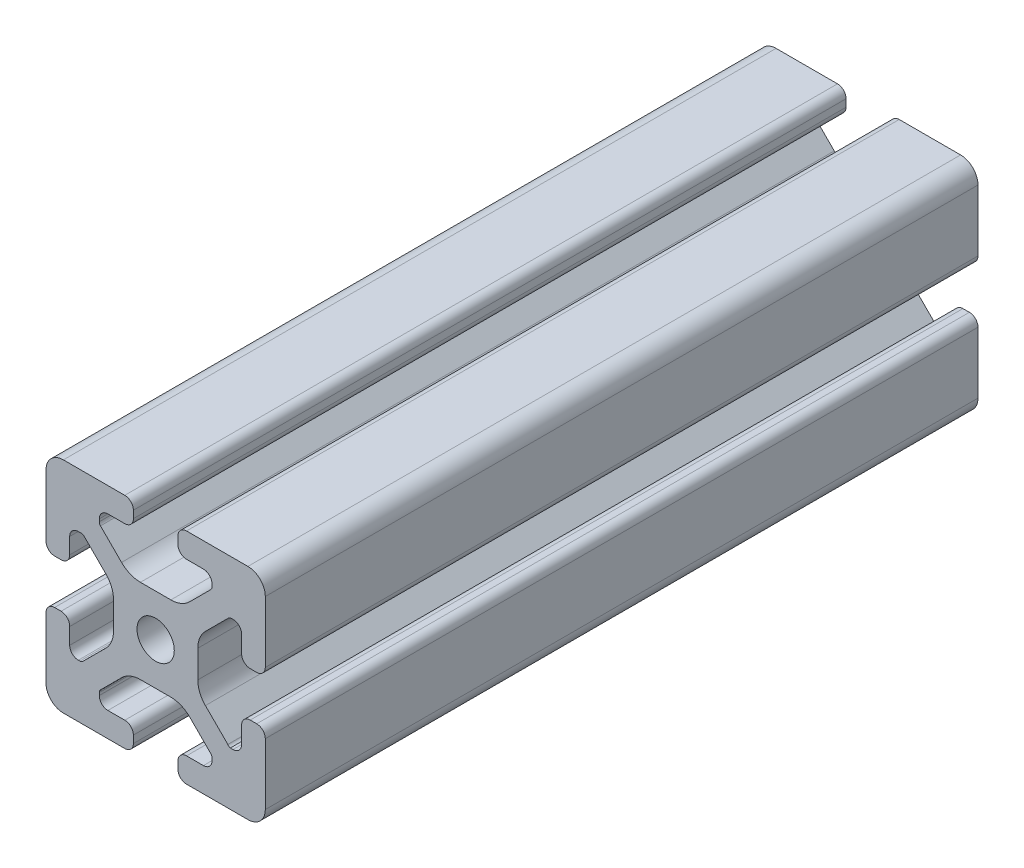
from build123d import *

# Parameters (mm, degrees)
SKETCH1_R      = 3.4
EXTRUDE1_DEPTH = 130


with BuildPart() as part:
    # Sketch1 → Extrude1 (new body)
    with BuildSketch(Plane.XY):
        with BuildLine():
            Line((-8.715, -15.524615034), (-5.63, -15.524615034))
            ThreePointArc((-5.63, -15.524615034), (-4.519842354, -15.984457388), (-4.06, -17.094615034))
            Line((-4.06, -17.094615034), (-4.06, -18.43))
            ThreePointArc((-4.06, -18.43), (-4.519842354, -19.540157646), (-5.63, -20))
            Line((-5.63, -20), (-16.674615034, -20))
            ThreePointArc((-16.674615034, -20), (-18.951578385, -19.194274381), (-20, -17.018368134))
            Line((-20, -17.018368134), (-20, -5.757918808))
            ThreePointArc((-20, -5.757918808), (-19.564709668, -4.603883664), (-18.43, -4.120449326))
            Line((-18.43, -4.120449326), (-17.25, -4.120449326))
            ThreePointArc((-17.25, -4.120449326), (-16.115287682, -4.60388249), (-15.67999625, -5.757919334))
            Line((-15.67999625, -5.757919334), (-15.67999625, -8.715399492))
            ThreePointArc((-15.67999625, -8.715399492), (-15.220153896, -9.825557139), (-14.10999625, -10.285399492))
            Line((-14.10999625, -10.285399492), (-13.816898819, -10.285399492))
            ThreePointArc((-13.816898819, -10.285399492), (-13.526061711, -10.227547119), (-13.279501941, -10.062800646))
            Line((-13.279501941, -10.062800646), (-9.076242789, -5.859541495))
            ThreePointArc((-9.076242789, -5.859541495), (-8.046572221, -4.318530588), (-7.685, -2.500784284))
            Line((-7.685, -2.500784284), (-7.685, 2.500784284))
            ThreePointArc((-7.685, 2.500784284), (-8.046572221, 4.318530588), (-9.076242789, 5.859541495))
            Line((-9.076242789, 5.859541495), (-13.040489136, 9.823787841))
            ThreePointArc((-13.040489136, 9.823787841), (-13.354224618, 10.012729352), (-13.71989919, 10.033001362))
            Line((-13.71989919, 10.033001362), (-14.05520779, 10.044710596))
            ThreePointArc((-14.05520779, 10.044710596), (-15.200613642, 9.605030484), (-15.68, 8.475666998))
            Line((-15.68, 8.475666998), (-15.68, 5.572979049))
            ThreePointArc((-15.68, 5.572979049), (-16.139842354, 4.462821403), (-17.25, 4.002979049))
            Line((-17.25, 4.002979049), (-18.43, 4.002979049))
            ThreePointArc((-18.43, 4.002979049), (-19.540157646, 4.462821403), (-20, 5.572979049))
            Line((-20, 5.572979049), (-20, 13.004526564))
            Line((-20, 13.004526564), (-20, 16.83))
            ThreePointArc((-20, 16.83), (-19.071528496, 19.071528496), (-16.83, 20))
            Line((-16.83, 20), (-5.63, 20))
            ThreePointArc((-5.63, 20), (-4.519842354, 19.540157646), (-4.06, 18.43))
            Line((-4.06, 18.43), (-4.06, 17.094615034))
            ThreePointArc((-4.06, 17.094615034), (-4.519842354, 15.984457388), (-5.63, 15.524615034))
            Line((-5.63, 15.524615034), (-8.715, 15.524615034))
            ThreePointArc((-8.715, 15.524615034), (-9.825157646, 15.06477268), (-10.285, 13.954615034))
            Line((-10.285, 13.954615034), (-10.285, 13.492503602))
            ThreePointArc((-10.285, 13.492503602), (-10.227148445, 13.201664194), (-10.062401154, 12.955102448))
            Line((-10.062401154, 12.955102448), (-6.217092793, 9.109794088))
            ThreePointArc((-6.217092793, 9.109794088), (-4.63891877, 8.055291919), (-2.777335583, 7.685))
            Line((-2.777335583, 7.685), (2.777335583, 7.685))
            ThreePointArc((2.777335583, 7.685), (4.63891877, 8.055291919), (6.217092793, 9.109794088))
            Line((6.217092793, 9.109794088), (10.062401154, 12.955102448))
            ThreePointArc((10.062401154, 12.955102448), (10.227148445, 13.201664194), (10.285, 13.492503602))
            Line((10.285, 13.492503602), (10.285, 13.954615034))
            ThreePointArc((10.285, 13.954615034), (9.825157646, 15.06477268), (8.715, 15.524615034))
            Line((8.715, 15.524615034), (5.63, 15.524615034))
            ThreePointArc((5.63, 15.524615034), (4.519842354, 15.984457388), (4.06, 17.094615034))
            Line((4.06, 17.094615034), (4.06, 18.43))
            ThreePointArc((4.06, 18.43), (4.519842354, 19.540157646), (5.63, 20))
            Line((5.63, 20), (12.979635074, 20))
            Line((12.979635074, 20), (16.83, 20))
            ThreePointArc((16.83, 20), (19.071528496, 19.071528496), (20, 16.83))
            Line((20, 16.83), (20, 13.001098436))
            Line((20, 13.001098436), (20, 5.63))
            ThreePointArc((20, 5.63), (19.540157461, 4.519842693), (18.43, 4.060000526))
            Line((18.43, 4.060000526), (17.24999625, 4.060000526))
            ThreePointArc((17.24999625, 4.060000526), (16.139838603, 4.519842879), (15.67999625, 5.630000526))
            Line((15.67999625, 5.630000526), (15.67999625, 8.715399492))
            ThreePointArc((15.67999625, 8.715399492), (15.220153896, 9.825557139), (14.10999625, 10.285399492))
            Line((14.10999625, 10.285399492), (13.816903094, 10.285399492))
            ThreePointArc((13.816903094, 10.285399492), (13.526063686, 10.227547937), (13.279501941, 10.062800646))
            Line((13.279501941, 10.062800646), (9.076242789, 5.859541495))
            ThreePointArc((9.076242789, 5.859541495), (8.046572221, 4.318530588), (7.685, 2.500784284))
            Line((7.685, 2.500784284), (7.685, -2.500784284))
            ThreePointArc((7.685, -2.500784284), (8.046572221, -4.318530588), (9.076242789, -5.859541495))
            Line((9.076242789, -5.859541495), (13.163657296, -9.946956002))
            ThreePointArc((13.163657296, -9.946956002), (13.35903797, -10.160433474), (13.6200547, -10.285399492))
            Line((13.6200547, -10.285399492), (14.10999625, -10.285399492))
            ThreePointArc((14.10999625, -10.285399492), (15.220153896, -9.825557139), (15.67999625, -8.715399492))
            Line((15.67999625, -8.715399492), (15.67999625, -5.630000526))
            ThreePointArc((15.67999625, -5.630000526), (16.139838603, -4.519842879), (17.24999625, -4.060000526))
            Line((17.24999625, -4.060000526), (18.43, -4.060000526))
            ThreePointArc((18.43, -4.060000526), (19.540157461, -4.519842693), (20, -5.63))
            Line((20, -5.63), (20, -16.83))
            ThreePointArc((20, -16.83), (19.071528496, -19.071528496), (16.83, -20))
            Line((16.83, -20), (13, -20))
            Line((13, -20), (5.63, -20))
            ThreePointArc((5.63, -20), (4.519842354, -19.540157646), (4.06, -18.43))
            Line((4.06, -18.43), (4.06, -17.094615034))
            ThreePointArc((4.06, -17.094615034), (4.519842354, -15.984457388), (5.63, -15.524615034))
            Line((5.63, -15.524615034), (8.715, -15.524615034))
            ThreePointArc((8.715, -15.524615034), (9.825157646, -15.06477268), (10.285, -13.954615034))
            Line((10.285, -13.954615034), (10.285, -13.492503602))
            ThreePointArc((10.285, -13.492503602), (10.227148445, -13.201664194), (10.062401154, -12.955102448))
            Line((10.062401154, -12.955102448), (6.217092793, -9.109794088))
            ThreePointArc((6.217092793, -9.109794088), (4.63891877, -8.055291919), (2.777335583, -7.685))
            Line((2.777335583, -7.685), (-2.777335583, -7.685))
            ThreePointArc((-2.777335583, -7.685), (-4.63891877, -8.055291919), (-6.217092793, -9.109794088))
            Line((-6.217092793, -9.109794088), (-10.062401154, -12.955102448))
            ThreePointArc((-10.062401154, -12.955102448), (-10.227148445, -13.201664194), (-10.285, -13.492503602))
            Line((-10.285, -13.492503602), (-10.285, -13.954615034))
            ThreePointArc((-10.285, -13.954615034), (-9.825157646, -15.06477268), (-8.715, -15.524615034))
        make_face()
        Circle(SKETCH1_R, mode=Mode.SUBTRACT)
    extrude(amount=-EXTRUDE1_DEPTH)


solid = part.part
